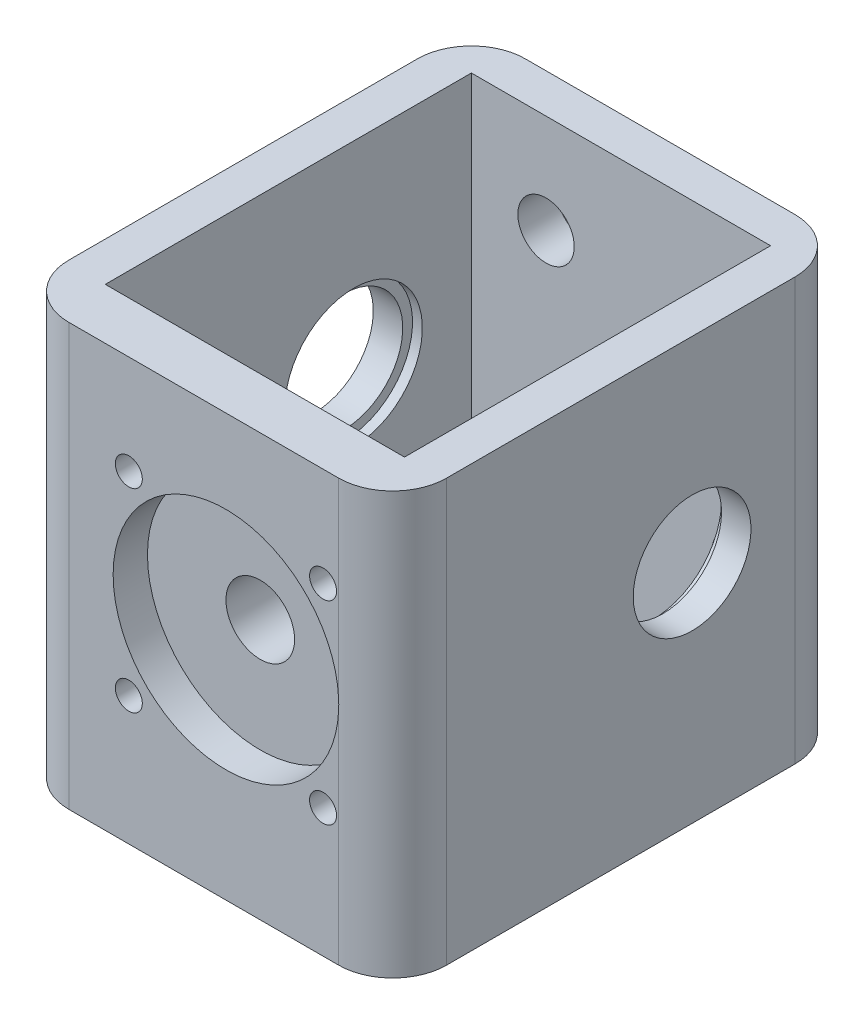
from build123d import *

# Parameters (mm, degrees)
BOSS_EXTRUDE1_DEPTH      = 20
BOSS_EXTRUDE1_DEPTH_BACK = 23
SKETCH5_W                = 30.5
SKETCH5_H                = 37.32
CUT_EXTRUDE1_DEPTH       = 40
SKETCH4_R                = 1.375
SKETCH4_R_2              = 11.5
SKETCH4_R_3              = 6
SKETCH4_R_4              = 3.5
BOSS_EXTRUDE2_DEPTH      = 6.81
SKETCH4_3_R              = 1.375
SKETCH4_3_R_2            = 3.5
CUT_EXTRUDE2_DEPTH       = 6.21
CUT_EXTRUDE2_DEPTH_BACK  = 6.81
CUT_EXTRUDE3_START       = -6.81
SKETCH4_4_R              = 6
SKETCH4_4_R_2            = 3.5
CUT_EXTRUDE3_DEPTH       = 3.5
CUT_EXTRUDE4_START       = 5.21
SKETCH4_5_R              = 11.5
CUT_EXTRUDE4_DEPTH       = 3.5
SKETCH6_R                = 6
CUT_EXTRUDE5_DEPTH       = 1
CUT_EXTRUDE5_DEPTH_BACK  = 39.5000001
CUT_EXTRUDE6_START       = -4
SKETCH6_3_R              = 7
SKETCH6_3_R_2            = 6
CUT_EXTRUDE6_DEPTH       = 1
CUT_EXTRUDE7_START       = -34.5
SKETCH6_4_R              = 7
SKETCH6_4_R_2            = 6
CUT_EXTRUDE7_DEPTH       = 1
SKETCH7_R                = 1.85
SKETCH7_R_2              = 4
CUT_EXTRUDE8_DEPTH       = 4.0000001
SKETCH8_R                = 2.875
CUT_EXTRUDE9_DEPTH       = 5


with BuildPart() as part:
    # Sketch3 → Boss-Extrude1 (new body, two sides)
    with BuildSketch(Plane(origin=(0, 0, 0), x_dir=(1, 0, 0), z_dir=(0, 1, 0))) as boss_extrude1_sk:
        with BuildLine():
            Line((-16.01, 16), (11.49, 16))
            ThreePointArc((11.49, 16), (15.379087297, 14.389087297), (16.99, 10.5))
            Line((16.99, 10.5), (16.99, -25.03))
            ThreePointArc((16.99, -25.03), (15.379087297, -28.919087297), (11.49, -30.53))
            Line((11.49, -30.53), (-16.01, -30.53))
            ThreePointArc((-16.01, -30.53), (-19.899087297, -28.919087297), (-21.51, -25.03))
            Line((-21.51, -25.03), (-21.51, 10.5))
            ThreePointArc((-21.51, 10.5), (-19.899087297, 14.389087297), (-16.01, 16))
        make_face()
    extrude(amount=BOSS_EXTRUDE1_DEPTH)
    extrude(boss_extrude1_sk.sketch, amount=-BOSS_EXTRUDE1_DEPTH_BACK)

    # Sketch5 → Cut-Extrude1 (cut)
    with BuildSketch(Plane(origin=(0, 20, 0), x_dir=(1, 0, 0), z_dir=(0, 1, 0))):
        with Locations((-2.26, -6.66)):
            Rectangle(SKETCH5_W, SKETCH5_H)
    extrude(amount=-CUT_EXTRUDE1_DEPTH, mode=Mode.SUBTRACT)

    # Sketch4 → Boss-Extrude2 (add)
    with BuildSketch(Plane.XY.offset(25.32)):
        with BuildLine():
            ThreePointArc((11.5, 0), (-1.557539449, -11.394036636), (-11.078099281, 3.08637592))
            Line((-11.078099281, 3.08637592), (-17.51, -20))
            Line((-17.51, -20), (12.99, -20))
            Line((12.99, -20), (11.469504194, 0.836942974))
            ThreePointArc((11.469504194, 0.836942974), (11.49237352, 0.41874919), (11.5, 0))
        make_face()
        with Locations((-9.9, -9.9)):
            Circle(SKETCH4_R, mode=Mode.SUBTRACT)
        with Locations((9.9, -9.9)):
            Circle(SKETCH4_R, mode=Mode.SUBTRACT)
        Circle(SKETCH4_R_2)
        with Locations((-9.9, -9.9)):
            Circle(SKETCH4_R)
        with Locations((9.9, -9.9)):
            Circle(SKETCH4_R)
        Circle(SKETCH4_R_3)
        Circle(SKETCH4_R_4, mode=Mode.SUBTRACT)
        Circle(SKETCH4_R_4)
    extrude(amount=-BOSS_EXTRUDE2_DEPTH)

    # Sketch4_3 → Cut-Extrude2 (cut, two sides)
    with BuildSketch(Plane.XY.offset(25.32)) as cut_extrude2_sk:
        with Locations((-9.9, 9.9)):
            Circle(SKETCH4_3_R)
        with Locations((-9.9, -9.9)):
            Circle(SKETCH4_3_R)
        with Locations((9.9, 9.9)):
            Circle(SKETCH4_3_R)
        with Locations((9.9, -9.9)):
            Circle(SKETCH4_3_R)
        Circle(SKETCH4_3_R_2)
    extrude(amount=CUT_EXTRUDE2_DEPTH, mode=Mode.SUBTRACT)
    extrude(cut_extrude2_sk.sketch, amount=-CUT_EXTRUDE2_DEPTH_BACK, mode=Mode.SUBTRACT)

    # Sketch4_4 → Cut-Extrude3 (cut)
    with BuildSketch(Plane.XY.offset(25.32).offset(CUT_EXTRUDE3_START)):
        Circle(SKETCH4_4_R)
        Circle(SKETCH4_4_R_2, mode=Mode.SUBTRACT)
    extrude(amount=CUT_EXTRUDE3_DEPTH, mode=Mode.SUBTRACT)

    # Sketch4_5 → Cut-Extrude4 (cut)
    with BuildSketch(Plane.XY.offset(25.32).offset(CUT_EXTRUDE4_START)):
        Circle(SKETCH4_5_R)
    extrude(amount=-CUT_EXTRUDE4_DEPTH, mode=Mode.SUBTRACT)

    # Sketch6 → Cut-Extrude5 (cut, two sides)
    with BuildSketch(Plane.ZY.offset(21.51)) as cut_extrude5_sk:
        Circle(SKETCH6_R)
    extrude(amount=CUT_EXTRUDE5_DEPTH, mode=Mode.SUBTRACT)
    extrude(cut_extrude5_sk.sketch, amount=-CUT_EXTRUDE5_DEPTH_BACK, mode=Mode.SUBTRACT)

    # Sketch6_3 → Cut-Extrude6 (cut)
    with BuildSketch(Plane.ZY.offset(21.51).offset(CUT_EXTRUDE6_START)):
        Circle(SKETCH6_3_R)
        Circle(SKETCH6_3_R_2, mode=Mode.SUBTRACT)
    extrude(amount=CUT_EXTRUDE6_DEPTH, mode=Mode.SUBTRACT)

    # Sketch6_4 → Cut-Extrude7 (cut)
    with BuildSketch(Plane.ZY.offset(21.51).offset(CUT_EXTRUDE7_START)):
        Circle(SKETCH6_4_R)
        Circle(SKETCH6_4_R_2, mode=Mode.SUBTRACT)
    extrude(amount=-CUT_EXTRUDE7_DEPTH, mode=Mode.SUBTRACT)

    # Sketch7 → Cut-Extrude8 (cut, through all)
    with BuildSketch(Plane(origin=(0, -20, 0), x_dir=(1, 0, 0), z_dir=(0, 1, 0))):
        with Locations((5.656854249, -5.656854249)):
            Circle(SKETCH7_R)
        with Locations((0, -8)):
            Circle(SKETCH7_R)
        with Locations((-5.656854249, -5.656854249)):
            Circle(SKETCH7_R)
        with Locations((-8, 0)):
            Circle(SKETCH7_R)
        with Locations((-5.656854249, 5.656854249)):
            Circle(SKETCH7_R)
        with Locations((0, 8)):
            Circle(SKETCH7_R)
        with Locations((5.656854249, 5.656854249)):
            Circle(SKETCH7_R)
        Circle(SKETCH7_R_2)
        with Locations((8, 0)):
            Circle(SKETCH7_R)
    extrude(amount=-CUT_EXTRUDE8_DEPTH, mode=Mode.SUBTRACT)

    # Sketch8 → Cut-Extrude9 (cut, through all)
    with BuildSketch(Plane.XY.offset(-12)):
        with Locations((-9.9, 9.9)):
            Circle(SKETCH8_R)
        with Locations((9.9, 9.9)):
            Circle(SKETCH8_R)
        with Locations((-9.9, -9.9)):
            Circle(SKETCH8_R)
        with Locations((9.9, -9.9)):
            Circle(SKETCH8_R)
    extrude(amount=-CUT_EXTRUDE9_DEPTH, mode=Mode.SUBTRACT)


solid = part.part
